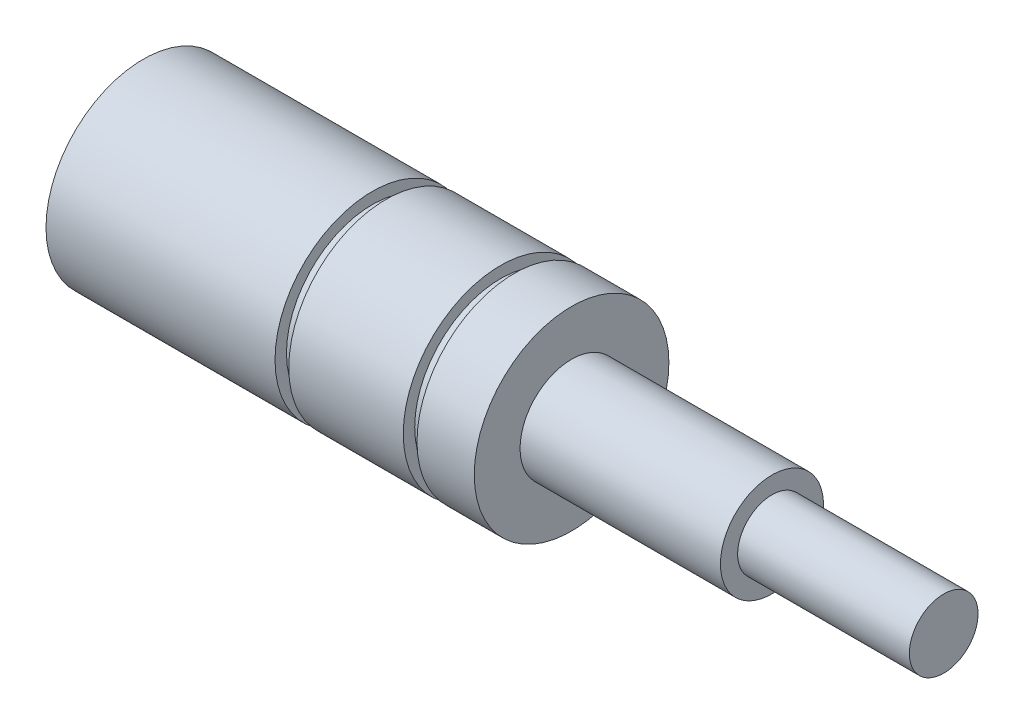
from build123d import *


with BuildPart() as part:
    # Sketch1 → Revolve1 (revolve)
    with BuildSketch(Plane.XY):
        Polygon((-21.4, 4.5), (0, 4.5), (0, 0), (48.5, 0), (48.5, 3), (33.5, 3), (33.5, 4.5), (16, 4.5), (16, 8.5), (11, 8.5), (11, 7.5), (9.8, 7.5), (9.8, 8.5), (-0.2, 8.5), (-0.2, 7.5), (-1.4, 7.5), (-1.4, 8.5), (-21.4, 8.5), align=None)
    revolve(axis=Axis((-48.510050734, 0, 0), (1, 0, 0)))


solid = part.part
